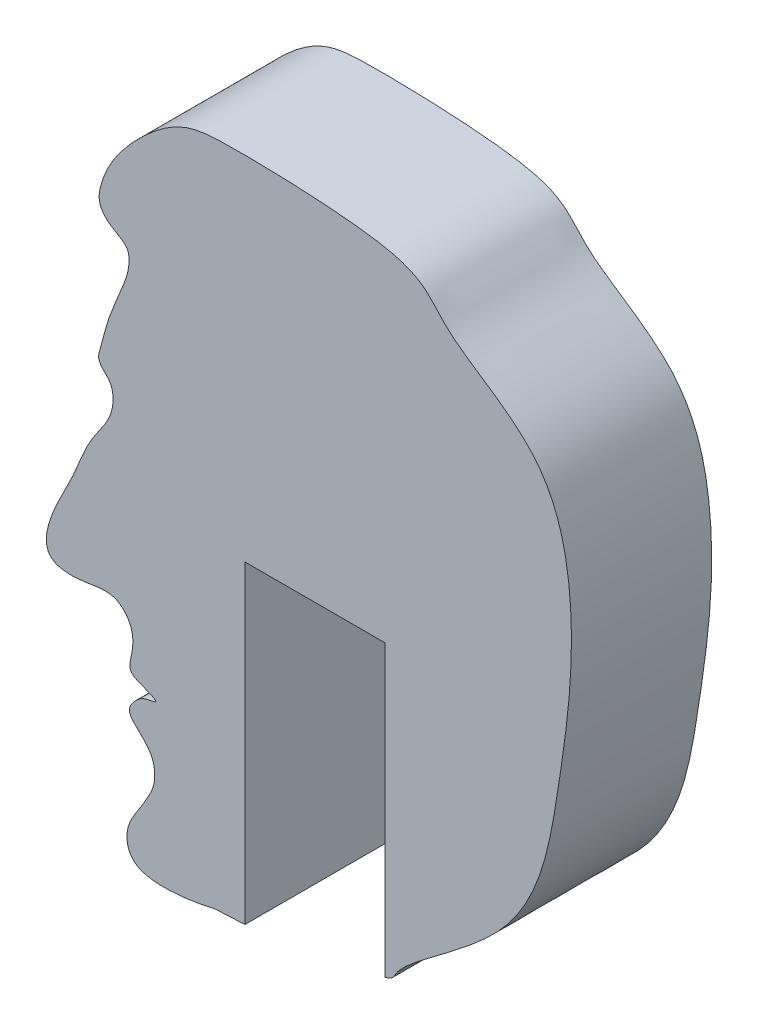
from build123d import *

# Parameters (mm, degrees)
BOSS_EXTRUDE5_DEPTH = 3


with BuildPart() as part:
    # Sketch3 → Boss-Extrude5 (new body)
    with BuildSketch(Plane.XY):
        with BuildLine():
            Line((1.8, -8.550495569), (1.8, -2.350495569))
            Line((1.8, -2.350495569), (-1.2, -2.350495569))
            Line((-1.2, -2.350495569), (-1.2, -9.070864624))
            add(Edge.make_bspline(
                [(1.8, -8.550495569), (1.983383354, -8.494478803), (2.056373377, -8.079229426), (4.964075713, -6.444498772), (5.537447722, -3.101318312), (5.985684206, 0.111969224), (5.297417514, 2.832114606), (2.713161282, 4.205661483), (2.790094307, 5.073725505), (-1.228411944, 5.223672352), (-2.592443394, 5.142456413), (-3.621049414, 4.287100176), (-4.217607014, 3.462826347), (-4.35564291, 2.748583301), (-4.090874346, 2.400529841), (-3.710191713, 2.288974102), (-3.652393503, 1.842122356), (-3.863531317, 1.320054122), (-4.149182127, 0.667065869), (-4.257215136, 0.162123331), (-4.346512775, -0.121912566), (-4.262104082, -0.304075751), (-4.076595097, -0.424060165), (-3.996920691, -0.734301628), (-4.074636025, -1.193153712), (-4.567205028, -1.749223711), (-4.822847968, -2.535955287), (-5.247678609, -3.285613193), (-5.689588863, -4.409578773), (-4.643096116, -4.495563355), (-4.052703464, -4.277721273), (-3.603187863, -4.712613501), (-3.565533961, -5.129976687), (-3.73206705, -5.649260123), (-3.387143041, -5.72985838), (-3.003181829, -5.909658994), (-3.377310332, -5.939096103), (-3.533738477, -6.076413575), (-3.761682577, -6.357034744), (-3.4206891, -6.658441296), (-3.134002275, -6.960575091), (-3.10469428, -7.427649382), (-3.281839957, -7.76662759), (-3.490180167, -8.114702816), (-3.782749366, -8.52236987), (-3.656923532, -9.461249721), (-2.064505283, -9.159116497), (-1.814807221, -9.08909307), (-1.290428413, -9.078744744), (-1.2, -9.070864624)],
                knots=[0.035721379, 0.035721379, 0.035721379, 0.035721379, 0.04811128, 0.116218424, 0.19621585, 0.287146162, 0.339827994, 0.385710093, 0.445307385, 0.49656977, 0.51729351, 0.547662027, 0.578023306, 0.585346504, 0.593439587, 0.6050414, 0.607152614, 0.62251563, 0.641304575, 0.654770406, 0.657233564, 0.660589327, 0.667149636, 0.671240491, 0.681073378, 0.696862324, 0.719662541, 0.733854218, 0.759566929, 0.772793823, 0.791587871, 0.797896073, 0.811273688, 0.818616701, 0.828455889, 0.832672088, 0.837704817, 0.843454138, 0.849075736, 0.857765982, 0.867553457, 0.877942684, 0.885823101, 0.892850099, 0.905030759, 0.918978952, 0.943844645, 0.947370899, 0.954241492, 0.954241492, 0.954241492, 0.954241492], degree=3))
        make_face()
    extrude(amount=BOSS_EXTRUDE5_DEPTH)


solid = part.part
